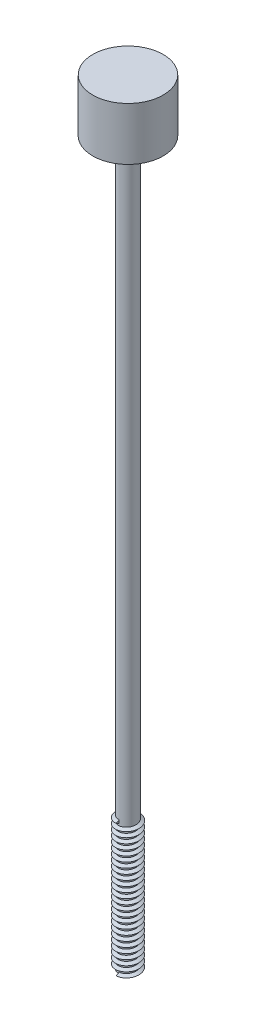
from build123d import *

# Parameters (mm, degrees)
SKETCH1_R                = 5
BOSS_EXTRUDE1_DEPTH      = 320
BOSS_EXTRUDE1_DEPTH_BACK = 90
SKETCH2_R                = 20
BOSS_EXTRUDE2_DEPTH      = 30
SWEEP1_PITCH             = 3
SWEEP1_HEIGHT            = 75
SWEEP1_RADIUS            = 5
SKETCH5_W                = 13.425190798
SKETCH5_H                = 62.245941315
CUT_EXTRUDE1_DEPTH       = 30
CUT_EXTRUDE1_DEPTH_BACK  = 30


with BuildPart() as part:
    # Sketch1 → Boss-Extrude1 (new, two sides)
    with BuildSketch(Plane(origin=(0, 0, 0), x_dir=(1, 0, 0), z_dir=(0, 1, 0))) as boss_extrude1_sk:
        with Locations(Location((0, 0, 0), (0, 0, 270))):
            Circle(SKETCH1_R)
    extrude(amount=BOSS_EXTRUDE1_DEPTH)
    extrude(boss_extrude1_sk.sketch, amount=-BOSS_EXTRUDE1_DEPTH_BACK)

    # Sketch2 → Boss-Extrude2 (add)
    with BuildSketch(Plane(origin=(0, 320, 0), x_dir=(1, 0, 0), z_dir=(0, 1, 0))):
        with Locations(Location((0, 0, 0), (0, 0, 270))):
            Circle(SKETCH2_R)
    extrude(amount=BOSS_EXTRUDE2_DEPTH)

    # Sweep1: sweep along a helix
    with BuildLine() as sweep1_path:
        Helix(SWEEP1_PITCH, SWEEP1_HEIGHT, SWEEP1_RADIUS, center=(0, -90, 0), direction=(0, 1, 0))
    # Sketch4 → Sweep1 (sweep)
    with BuildSketch(Plane(origin=(0, 0, 0), x_dir=(0, 0, -1), z_dir=(1, 0, 0))):
        Polygon((-6.7, -75), (-4.15, -76.472243186), (-4.15, -73.527756814), align=None)
    sweep(path=sweep1_path.line, is_frenet=True)

    # Sketch5 → Cut-Extrude1 (cut, two sides)
    with BuildSketch(Plane(origin=(0, 0, 0), x_dir=(0, 0, -1), z_dir=(1, 0, 0))) as cut_extrude1_sk:
        with Locations((-1.712595399, -121.122970658)):
            Rectangle(SKETCH5_W, SKETCH5_H)
    extrude(amount=CUT_EXTRUDE1_DEPTH, mode=Mode.SUBTRACT)
    extrude(cut_extrude1_sk.sketch, amount=-CUT_EXTRUDE1_DEPTH_BACK, mode=Mode.SUBTRACT)


solid = part.part
